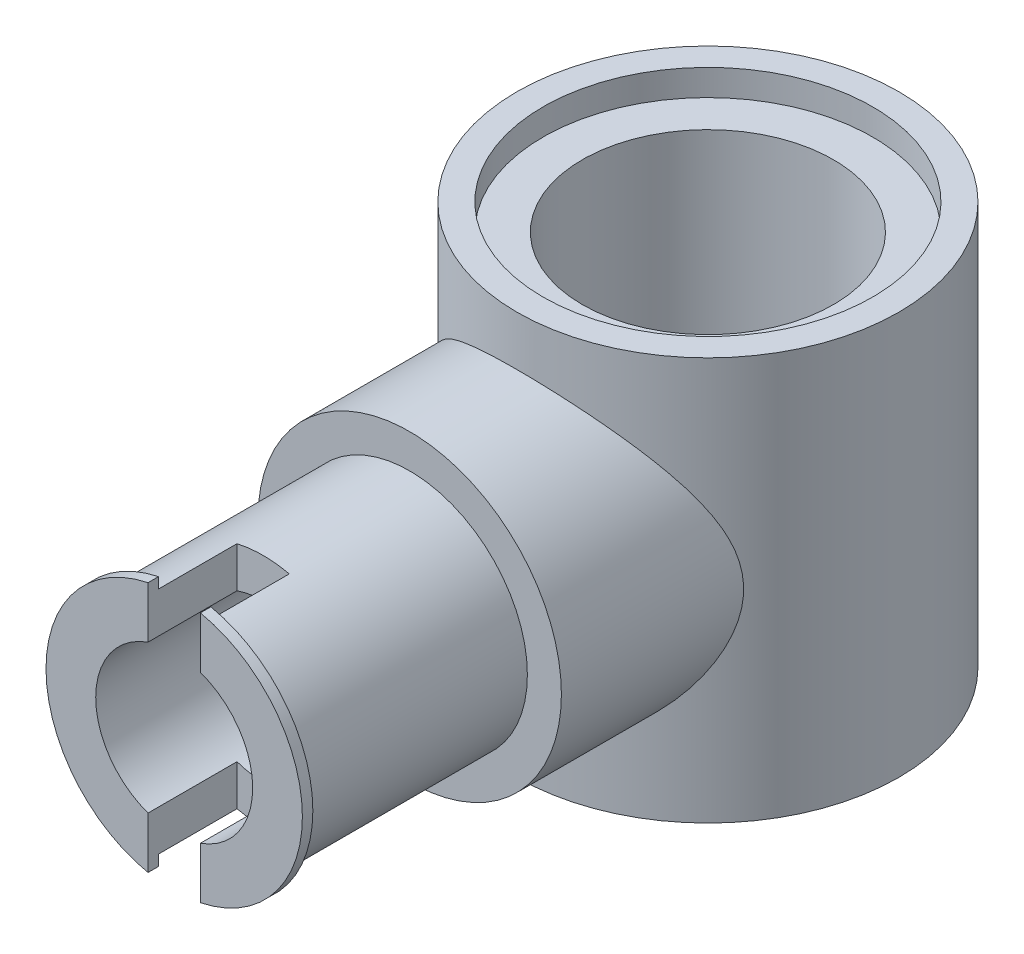
from build123d import *

# Parameters (mm, degrees)
SKETCH1_R           = 3.65
SKETCH1_R_2         = 2.4
BOSS_EXTRUDE1_DEPTH = 7.7
SKETCH2_R           = 3.15
SKETCH2_R_2         = 2.4
CUT_EXTRUDE1_DEPTH  = 0.5
SKETCH4_R           = 2.9
BOSS_EXTRUDE2_DEPTH = 5.7
SKETCH5_R           = 2.25
BOSS_EXTRUDE3_DEPTH = 10.2
SKETCH8_R           = 2.4
CUT_EXTRUDE5_DEPTH  = 8.2000001
SKETCH14_R          = 2.45
SKETCH14_R_2        = 2.25
BOSS_EXTRUDE5_DEPTH = 0.2
SKETCH10_R          = 1.5
CUT_EXTRUDE6_DEPTH  = 8.35
SKETCH7_W           = 1
SKETCH7_H           = 5.978668982
CUT_EXTRUDE7_DEPTH  = 1.7


with BuildPart() as part:
    # Sketch1 → Boss-Extrude1 (new body)
    with BuildSketch(Plane(origin=(0, 0, 0), x_dir=(1, 0, 0), z_dir=(0, 1, 0))):
        Circle(SKETCH1_R)
        Circle(SKETCH1_R_2, mode=Mode.SUBTRACT)
    extrude(amount=BOSS_EXTRUDE1_DEPTH)

    # Sketch2 → Cut-Extrude1 (cut)
    with BuildSketch(Plane(origin=(0, 7.7, 0), x_dir=(1, 0, 0), z_dir=(0, 1, 0))):
        Circle(SKETCH2_R)
        Circle(SKETCH2_R_2, mode=Mode.SUBTRACT)
    extrude(amount=-CUT_EXTRUDE1_DEPTH, mode=Mode.SUBTRACT)

    # Sketch4 → Boss-Extrude2 (add)
    with BuildSketch(Plane.XY):
        with Locations((0, 3.85)):
            Circle(SKETCH4_R)
    extrude(amount=BOSS_EXTRUDE2_DEPTH)

    # Sketch5 → Boss-Extrude3 (add)
    with BuildSketch(Plane.XY):
        with Locations((0, 3.85)):
            Circle(SKETCH5_R)
    extrude(amount=BOSS_EXTRUDE3_DEPTH)

    # Sketch8 → Cut-Extrude5 (cut, through all)
    with BuildSketch(Plane(origin=(0, 7.2, 0), x_dir=(1, 0, 0), z_dir=(0, 1, 0))):
        Circle(SKETCH8_R)
    extrude(amount=-CUT_EXTRUDE5_DEPTH, mode=Mode.SUBTRACT)

    # Sketch14 → Boss-Extrude5 (add)
    with BuildSketch(Plane.XY.offset(10)):
        with Locations((0, 3.85)):
            Circle(SKETCH14_R)
        with Locations((0, 3.85)):
            Circle(SKETCH14_R_2, mode=Mode.SUBTRACT)
    extrude(amount=BOSS_EXTRUDE5_DEPTH)

    # Sketch10 → Cut-Extrude6 (cut, through all)
    with BuildSketch(Plane.XY.offset(2.85)):
        with Locations((0, 3.85)):
            Circle(SKETCH10_R)
    extrude(amount=CUT_EXTRUDE6_DEPTH, mode=Mode.SUBTRACT)

    # Sketch7 → Cut-Extrude7 (cut)
    with BuildSketch(Plane.XY.offset(10.2)):
        with Locations((0, 3.85)):
            Rectangle(SKETCH7_W, SKETCH7_H)
    extrude(amount=-CUT_EXTRUDE7_DEPTH, mode=Mode.SUBTRACT)


solid = part.part
